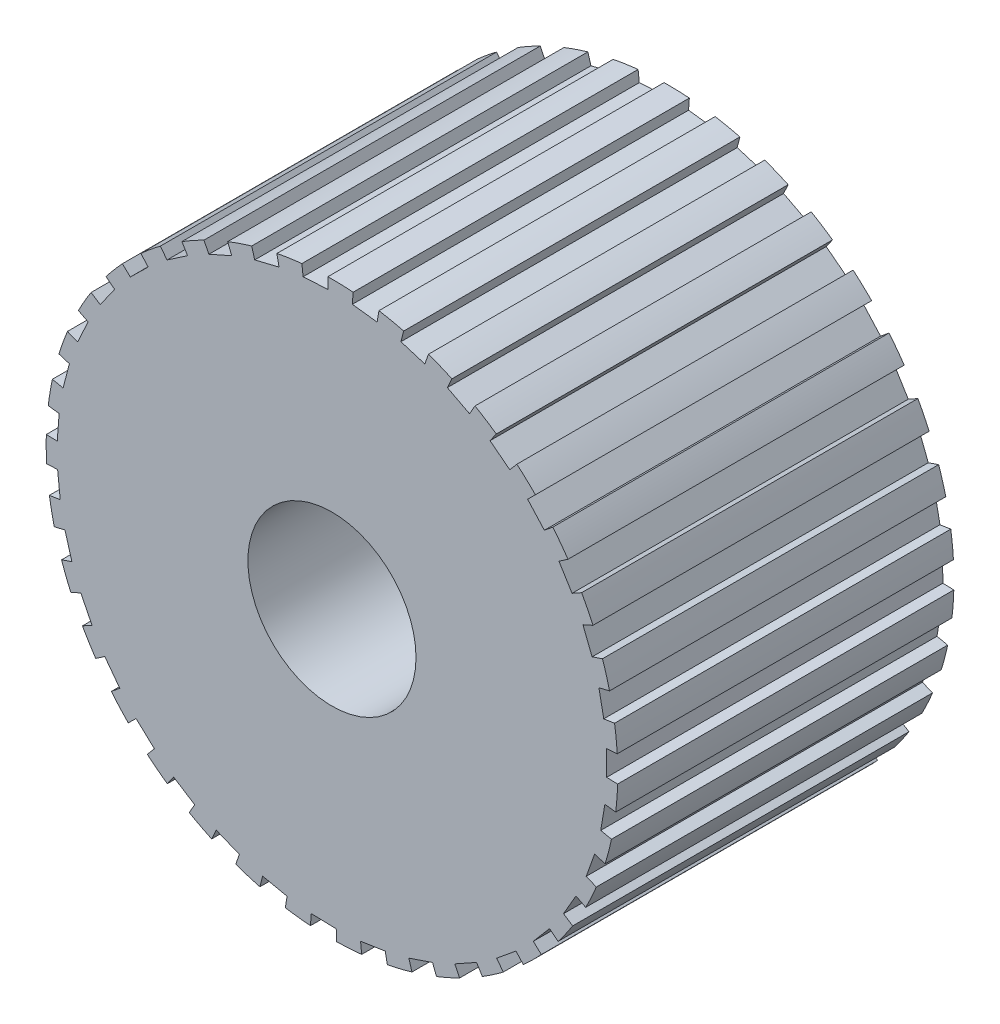
from build123d import *

# Parameters (mm, degrees)
BOSS_EXTRUDE1_DEPTH = 10
SKETCH2_R           = 2.5
CUT_EXTRUDE1_DEPTH  = 11


with BuildPart() as part:
    # Sketch1 → Boss-Extrude1 (new body)
    with BuildSketch(Plane.XY):
        with BuildLine():
            Line((-2.297240152, 7.844835842), (-2.388779771, 8.157434107))
            ThreePointArc((-2.388779771, 8.157434107), (-2.74754438, 8.043693174), (-3.100922317, 7.914182256))
            Line((-3.100922317, 7.914182256), (-2.982092925, 7.610905563))
            Line((-2.982092925, 7.610905563), (-3.661072086, 7.308578034))
            Line((-3.661072086, 7.308578034), (-3.806957201, 7.599807686))
            ThreePointArc((-3.806957201, 7.599807686), (-4.139647087, 7.423834723), (-4.464221028, 7.233307031))
            Line((-4.464221028, 7.233307031), (-4.293149129, 6.956121926))
            Line((-4.293149129, 6.956121926), (-4.90723415, 6.537416515))
            Line((-4.90723415, 6.537416515), (-5.102775894, 6.797917194))
            ThreePointArc((-5.102775894, 6.797917194), (-5.398698131, 6.565368115), (-5.684036002, 6.319947367))
            Line((-5.684036002, 6.319947367), (-5.466219987, 6.077762808))
            Line((-5.466219987, 6.077762808), (-5.995673672, 5.55613705))
            Line((-5.995673672, 5.55613705), (-6.234587172, 5.777536049))
            ThreePointArc((-6.234587172, 5.777536049), (-6.484230575, 5.495885174), (-6.721161383, 5.203459394))
            Line((-6.721161383, 5.203459394), (-6.463602037, 5.004059392))
            Line((-6.463602037, 5.004059392), (-6.891407308, 4.396278769))
            Line((-6.891407308, 4.396278769), (-7.166013687, 4.571460142))
            ThreePointArc((-7.166013687, 4.571460142), (-7.361354513, 4.249759962), (-7.542263106, 3.919727955))
            Line((-7.542263106, 3.919727955), (-7.2532386, 3.76952139))
            Line((-7.2532386, 3.76952139), (-7.565645443, 3.095120471))
            Line((-7.565645443, 3.095120471), (-7.867118627, 3.218453745))
            ThreePointArc((-7.867118627, 3.218453745), (-8.00187846, 2.867043968), (-8.120950287, 2.510013234))
            Line((-8.120950287, 2.510013234), (-7.809750106, 2.413827869))
            Line((-7.809750106, 2.413827869), (-7.996717508, 1.694482454))
            Line((-7.996717508, 1.694482454), (-8.315367901, 1.762003596))
            ThreePointArc((-8.315367901, 1.762003596), (-8.385215449, 1.392178821), (-8.438623444, 1.019624623))
            Line((-8.438623444, 1.019624623), (-8.115249818, 0.980551934))
            Line((-8.115249818, 0.980551934), (-8.170768494, 0.239382377))
            Line((-8.170768494, 0.239382377), (-8.496354409, 0.248921202))
            ThreePointArc((-8.496354409, 0.248921202), (-8.499044715, -0.127432098), (-8.4850723, -0.503535563))
            Line((-8.4850723, -0.503535563), (-8.159918723, -0.484239747))
            Line((-8.159918723, -0.484239747), (-8.082204256, -1.223411647))
            Line((-8.082204256, -1.223411647), (-8.404261095, -1.272161724))
            ThreePointArc((-8.404261095, -1.272161724), (-8.33970769, -1.642947245), (-8.258803951, -2.010511701))
            Line((-8.258803951, -2.010511701), (-7.942321126, -1.933467564))
            Line((-7.942321126, -1.933467564), (-7.733871324, -2.646884213))
            Line((-7.733871324, -2.646884213), (-8.042047914, -2.752356326))
            ThreePointArc((-8.042047914, -2.752356326), (-7.912325598, -3.105656715), (-7.767090848, -3.452868339))
            Line((-7.767090848, -3.452868339), (-7.469450794, -3.320552143))
            Line((-7.469450794, -3.320552143), (-7.136965404, -3.985283743))
            Line((-7.136965404, -3.985283743), (-7.421356697, -4.144087931))
            ThreePointArc((-7.421356697, -4.144087931), (-7.230634851, -4.468547824), (-7.025737053, -4.784246948))
            Line((-7.025737053, -4.784246948), (-6.756506167, -4.600911443))
            Line((-6.756506167, -4.600911443), (-6.310671544, -5.195592975))
            Line((-6.310671544, -5.195592975), (-6.562136969, -5.40262514))
            ThreePointArc((-6.562136969, -5.40262514), (-6.316545551, -5.687816128), (-6.05857029, -5.961855923))
            Line((-6.05857029, -5.961855923), (-5.826401873, -5.733393665))
            Line((-5.826401873, -5.733393665), (-5.281547508, -6.238911573))
            Line((-5.281547508, -6.238911573), (-5.492004759, -6.487517532))
            ThreePointArc((-5.492004759, -6.487517532), (-5.199437279, -6.724273342), (-4.896676092, -6.947845943))
            Line((-4.896676092, -6.947845943), (-4.709032228, -6.681599896))
            Line((-4.709032228, -6.681599896), (-4.082670189, -7.08170642))
            Line((-4.082670189, -7.08170642), (-4.245354998, -7.363895772))
            ThreePointArc((-4.245354998, -7.363895772), (-3.915214815, -7.544606879), (-3.577398695, -7.710526478))
            Line((-3.577398695, -7.710526478), (-3.440310413, -7.415054009))
            Line((-3.440310413, -7.415054009), (-2.752572491, -7.696889396))
            Line((-2.752572491, -7.696889396), (-2.862256034, -8.003592343))
            ThreePointArc((-2.862256034, -8.003592343), (-2.505154125, -8.122450542), (-2.143140761, -8.225384348))
            Line((-2.143140761, -8.225384348), (-2.061014191, -7.910182185))
            Line((-2.061014191, -7.910182185), (-1.334004849, -8.064688014))
            Line((-1.334004849, -8.064688014), (-1.387161806, -8.386046871))
            ThreePointArc((-1.387161806, -8.386046871), (-1.014575721, -8.439231962), (-0.64000052, -8.475871597))
            Line((-0.64000052, -8.475871597), (-0.615475277, -8.151070597))
            Line((-0.615475277, -8.151070597), (0.127438807, -8.173280923))
            Line((0.127438807, -8.173280923), (0.132516944, -8.498966952))
            ThreePointArc((0.132516944, -8.498966952), (0.508611982, -8.484769523), (0.883709865, -8.453937359))
            Line((0.883709865, -8.453937359), (0.849845519, -8.129976894))
            Line((0.849845519, -8.129976894), (1.584786475, -8.019177858))
            Line((1.584786475, -8.019177858), (1.64793649, -8.338723243))
            ThreePointArc((1.64793649, -8.338723243), (2.015452477, -8.25759961), (2.379017088, -8.160286619))
            Line((2.379017088, -8.160286619), (2.287851581, -7.847579043))
            Line((2.287851581, -7.847579043), (2.991197802, -7.607331819))
            Line((2.991197802, -7.607331819), (3.110390002, -7.910466107))
            ThreePointArc((3.110390002, -7.910466107), (3.457514671, -7.765023651), (3.797860744, -7.604357552))
            Line((3.797860744, -7.604357552), (3.65232421, -7.312953546))
            Line((3.65232421, -7.312953546), (4.30146957, -6.950979876))
            Line((4.30146957, -6.950979876), (4.47287302, -7.227960082))
            ThreePointArc((4.47287302, -7.227960082), (4.788449499, -7.022873443), (5.09463803, -6.804018176))
            Line((5.09463803, -6.804018176), (4.899408135, -6.543283704))
            Line((4.899408135, -6.543283704), (5.473488567, -6.07121772))
            Line((5.473488567, -6.07121772), (5.691594218, -6.313141473))
            ThreePointArc((5.691594218, -6.313141473), (5.96547962, -6.055002304), (6.227669459, -5.784992058))
            Line((6.227669459, -5.784992058), (5.98902105, -5.56330734))
            Line((5.98902105, -5.56330734), (6.469585137, -4.996321632))
            Line((6.469585137, -4.996321632), (6.727382895, -5.195413302))
            ThreePointArc((6.727382895, -5.195413302), (6.950774318, -4.892518409), (7.160538467, -4.580031535))
            Line((7.160538467, -4.580031535), (6.886141901, -4.4045217))
            Line((6.886141901, -4.4045217), (7.257743919, -3.760839655))
            Line((7.257743919, -3.760839655), (7.546947951, -3.910700273))
            ThreePointArc((7.546947951, -3.910700273), (7.71266541, -3.572784946), (7.863261877, -3.22786503))
            Line((7.863261877, -3.22786503), (7.561936486, -3.10417111))
            Line((7.561936486, -3.10417111), (7.812632839, -2.404481197))
            Line((7.812632839, -2.404481197), (8.12394789, -2.50029412))
            ThreePointArc((8.12394789, -2.50029412), (8.22666509, -2.138219236), (8.31325358, -1.771952288))
            Line((8.31325358, -1.771952288), (7.99468421, -1.704049905))
            Line((7.99468421, -1.704049905), (8.116417311, -0.970840735))
            Line((8.116417311, -0.970840735), (8.439837459, -1.009526456))
            ThreePointArc((8.439837459, -1.009526456), (8.476252984, -0.634929401), (8.496050473, -0.259087541))
            Line((8.496050473, -0.259087541), (8.170476205, -0.249159135))
            Line((8.170476205, -0.249159135), (8.159333453, 0.494003347))
            Line((8.159333453, 0.494003347), (8.484463708, 0.513688219))
            ThreePointArc((8.484463708, 0.513688219), (8.453407134, 0.888767589), (8.405777314, 1.262104493))
            Line((8.405777314, 1.262104493), (8.083662373, 1.213739815))
            Line((8.083662373, 1.213739815), (7.940001904, 1.942969755))
            Line((7.940001904, 1.942969755), (8.256392313, 2.020392532))
            ThreePointArc((8.256392313, 2.020392532), (8.158861823, 2.383898856), (8.045335555, 2.74273145))
            Line((8.045335555, 2.74273145), (7.73703298, 2.637628169))
            Line((7.73703298, 2.637628169), (7.46547216, 3.329487516))
            Line((7.46547216, 3.329487516), (7.762953675, 3.462159766))
            ThreePointArc((7.762953675, 3.462159766), (7.60208398, 3.802409653), (7.426310092, 4.135204762))
            Line((7.426310092, 4.135204762), (7.141728982, 3.976740983))
            Line((7.141728982, 3.976740983), (6.750995999, 4.608992809))
            Line((6.750995999, 4.608992809), (7.020007318, 4.792650337))
            ThreePointArc((7.020007318, 4.792650337), (6.800968902, 5.098707875), (6.568596912, 5.39476919))
            Line((6.568596912, 5.39476919), (6.316883938, 5.18803807))
            Line((6.316883938, 5.18803807), (5.819537272, 5.740361281))
            Line((5.819537272, 5.740361281), (6.051432151, 5.969101182))
            ThreePointArc((6.051432151, 5.969101182), (5.781265088, 6.23112943), (5.499763622, 6.480941297))
            Line((5.499763622, 6.480941297), (5.289009046, 6.232587345))
            Line((5.289009046, 6.232587345), (4.701033829, 6.687229818))
            Line((4.701033829, 6.687229818), (4.888358974, 6.953700205))
            ThreePointArc((4.888358974, 6.953700205), (4.575746658, 7.163277359), (4.254163405, 7.358810619))
            Line((4.254163405, 7.358810619), (4.091141052, 7.076816134))
            Line((4.091141052, 7.076816134), (3.43143529, 7.419165287))
            Line((3.43143529, 7.419165287), (3.568169919, 7.714801581))
            ThreePointArc((3.568169919, 7.714801581), (3.223159965, 7.86519166), (2.871830875, 8.000161712))
            Line((2.871830875, 8.000161712), (2.761780418, 7.693590229))
            Line((2.761780418, 7.693590229), (2.051547597, 7.912642678))
            Line((2.051547597, 7.912642678), (2.133296946, 8.227942886))
            ThreePointArc((2.133296946, 8.227942886), (1.766978258, 8.314312229), (1.397195338, 8.384381026))
            Line((1.397195338, 8.384381026), (1.34365389, 8.063086005))
            Line((1.34365389, 8.063086005), (0.605721477, 8.151801224))
            Line((0.605721477, 8.151801224), (0.629858054, 8.476631337))
            ThreePointArc((0.629858054, 8.476631337), (0.254004417, 8.496203962), (-0.122347206, 8.499119434))
            Line((-0.122347206, 8.499119434), (-0.117658781, 8.173427562))
            Line((-0.117658781, 8.173427562), (-0.85957303, 8.12895417))
            Line((-0.85957303, 8.12895417), (-0.893824994, 8.452873883))
            ThreePointArc((-0.893824994, 8.452873883), (-1.267133336, 8.405020708), (-1.637957411, 8.340689151))
            Line((-1.637957411, 8.340689151), (-1.575189801, 8.021068432))
            Line((-1.575189801, 8.021068432), (-2.297240152, 7.844835842))
        make_face()
    extrude(amount=BOSS_EXTRUDE1_DEPTH)

    # Sketch2 → Cut-Extrude1 (cut, through all)
    with BuildSketch(Plane.XY.offset(10)):
        Circle(SKETCH2_R)
    extrude(amount=-CUT_EXTRUDE1_DEPTH, mode=Mode.SUBTRACT)


solid = part.part
